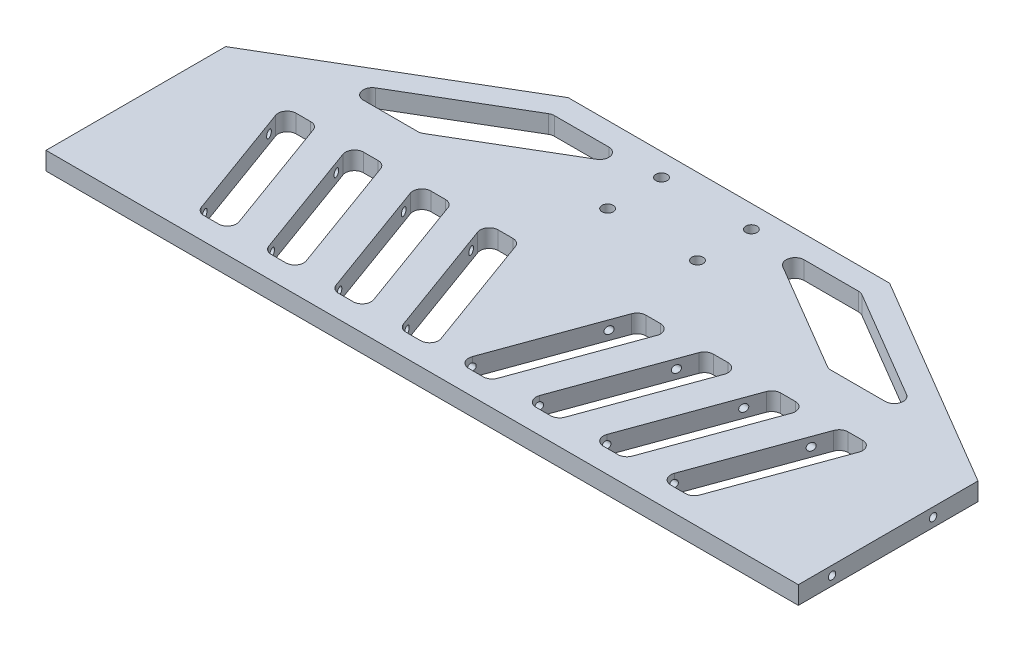
from build123d import *

# Parameters (mm, degrees)
SKIZZE3_R                       = 2.5
AUFSATZ_LINEAR_AUSTRAGEN2_DEPTH = 8
M4_GEWINDEBOHRUNG1_D            = 3.3
SCHNITT_LINEAR_AUSTRAGEN1_DEPTH = 8
SCHNITT_LINEAR_AUSTRAGEN2_DEPTH = 8


with BuildPart() as part:
    # Skizze3 → Aufsatz-Linear austragen2 (new body)
    with BuildSketch(Plane(origin=(0, 0, 0), x_dir=(1, 0, 0), z_dir=(0, 1, 0))):
        Polygon((167.5, -40), (-167.5, -40), (-167.5, 40), (-71.555705065, 96.578304299), (71.555705065, 96.578304299), (167.5, 40), align=None)
        with Locations((-20, 86.578304299)):
            Circle(SKIZZE3_R, mode=Mode.SUBTRACT)
        with Locations((-20, 62.578304299)):
            Circle(SKIZZE3_R, mode=Mode.SUBTRACT)
        with Locations((20, 62.578304299)):
            Circle(SKIZZE3_R, mode=Mode.SUBTRACT)
        with Locations((20, 86.578304299)):
            Circle(SKIZZE3_R, mode=Mode.SUBTRACT)
    extrude(amount=AUFSATZ_LINEAR_AUSTRAGEN2_DEPTH)

    # M4 Gewindebohrung1 (through all)
    with Locations(Plane(origin=(167.5, 0, 0), x_dir=(0, 0, -1), z_dir=(1, 0, 0))):
        with Locations((-25, 4), (20, 4)):
            Hole(M4_GEWINDEBOHRUNG1_D / 2)

    # Skizze7 → Schnitt-Linear austragen1 (cut)
    with BuildSketch(Plane(origin=(0, 8, 0), x_dir=(1, 0, 0), z_dir=(0, 1, 0))):
        with BuildLine():
            Line((-36.125622029, 30), (-29.639044209, 30))
            ThreePointArc((-29.639044209, 30), (-27.344738463, 29.276608177), (-25.880273726, 27.368080573))
            Line((-25.880273726, 27.368080573), (-6.953821544, -24.631919427))
            ThreePointArc((-6.953821544, -24.631919427), (-7.43598385, -28.294305745), (-10.712592027, -30))
            Line((-10.712592027, -30), (-17.199169847, -30))
            ThreePointArc((-17.199169847, -30), (-19.493475593, -29.276608177), (-20.95794033, -27.368080573))
            Line((-20.95794033, -27.368080573), (-39.884392512, 24.631919427))
            ThreePointArc((-39.884392512, 24.631919427), (-39.402230206, 28.294305745), (-36.125622029, 30))
        make_face()
        with BuildLine():
            Line((-55.880273726, 27.368080573), (-36.953821544, -24.631919427))
            ThreePointArc((-36.953821544, -24.631919427), (-37.43598385, -28.294305745), (-40.712592027, -30))
            Line((-40.712592027, -30), (-47.199169847, -30))
            ThreePointArc((-47.199169847, -30), (-49.493475593, -29.276608177), (-50.95794033, -27.368080573))
            Line((-50.95794033, -27.368080573), (-69.884392512, 24.631919427))
            ThreePointArc((-69.884392512, 24.631919427), (-69.402230206, 28.294305745), (-66.125622029, 30))
            Line((-66.125622029, 30), (-59.639044209, 30))
            ThreePointArc((-59.639044209, 30), (-57.344738463, 29.276608177), (-55.880273726, 27.368080573))
        make_face()
        with BuildLine():
            Line((-85.880273726, 27.368080573), (-66.953821544, -24.631919427))
            ThreePointArc((-66.953821544, -24.631919427), (-67.43598385, -28.294305745), (-70.712592027, -30))
            Line((-70.712592027, -30), (-77.199169847, -30))
            ThreePointArc((-77.199169847, -30), (-79.493475593, -29.276608177), (-80.95794033, -27.368080573))
            Line((-80.95794033, -27.368080573), (-99.884392512, 24.631919427))
            ThreePointArc((-99.884392512, 24.631919427), (-99.402230206, 28.294305745), (-96.125622029, 30))
            Line((-96.125622029, 30), (-89.639044209, 30))
            ThreePointArc((-89.639044209, 30), (-87.344738463, 29.276608177), (-85.880273726, 27.368080573))
        make_face()
        with BuildLine():
            Line((-115.880273726, 27.368080573), (-96.953821544, -24.631919427))
            ThreePointArc((-96.953821544, -24.631919427), (-97.43598385, -28.294305745), (-100.712592027, -30))
            Line((-100.712592027, -30), (-107.199169847, -30))
            ThreePointArc((-107.199169847, -30), (-109.493475593, -29.276608177), (-110.95794033, -27.368080573))
            Line((-110.95794033, -27.368080573), (-129.884392512, 24.631919427))
            ThreePointArc((-129.884392512, 24.631919427), (-129.402230206, 28.294305745), (-126.125622029, 30))
            Line((-126.125622029, 30), (-119.639044209, 30))
            ThreePointArc((-119.639044209, 30), (-117.344738463, 29.276608177), (-115.880273726, 27.368080573))
        make_face()
        with BuildLine():
            Line((126.125622029, 30), (119.639044209, 30))
            ThreePointArc((119.639044209, 30), (117.344738463, 29.276608177), (115.880273726, 27.368080573))
            Line((115.880273726, 27.368080573), (96.953821544, -24.631919427))
            ThreePointArc((96.953821544, -24.631919427), (97.43598385, -28.294305745), (100.712592027, -30))
            Line((100.712592027, -30), (107.199169847, -30))
            ThreePointArc((107.199169847, -30), (109.493475593, -29.276608177), (110.95794033, -27.368080573))
            Line((110.95794033, -27.368080573), (129.884392512, 24.631919427))
            ThreePointArc((129.884392512, 24.631919427), (129.402230206, 28.294305745), (126.125622029, 30))
        make_face()
        with BuildLine():
            Line((96.125622029, 30), (89.639044209, 30))
            ThreePointArc((89.639044209, 30), (87.344738463, 29.276608177), (85.880273726, 27.368080573))
            Line((85.880273726, 27.368080573), (66.953821544, -24.631919427))
            ThreePointArc((66.953821544, -24.631919427), (67.43598385, -28.294305745), (70.712592027, -30))
            Line((70.712592027, -30), (77.199169847, -30))
            ThreePointArc((77.199169847, -30), (79.493475593, -29.276608177), (80.95794033, -27.368080573))
            Line((80.95794033, -27.368080573), (99.884392512, 24.631919427))
            ThreePointArc((99.884392512, 24.631919427), (99.402230206, 28.294305745), (96.125622029, 30))
        make_face()
        with BuildLine():
            Line((66.125622029, 30), (59.639044209, 30))
            ThreePointArc((59.639044209, 30), (57.344738463, 29.276608177), (55.880273726, 27.368080573))
            Line((55.880273726, 27.368080573), (36.953821544, -24.631919427))
            ThreePointArc((36.953821544, -24.631919427), (37.43598385, -28.294305745), (40.712592027, -30))
            Line((40.712592027, -30), (47.199169847, -30))
            ThreePointArc((47.199169847, -30), (49.493475593, -29.276608177), (50.95794033, -27.368080573))
            Line((50.95794033, -27.368080573), (69.884392512, 24.631919427))
            ThreePointArc((69.884392512, 24.631919427), (69.402230206, 28.294305745), (66.125622029, 30))
        make_face()
        with BuildLine():
            Line((17.199169847, -30), (10.712592027, -30))
            ThreePointArc((10.712592027, -30), (7.43598385, -28.294305745), (6.953821544, -24.631919427))
            Line((6.953821544, -24.631919427), (25.880273726, 27.368080573))
            ThreePointArc((25.880273726, 27.368080573), (27.344738463, 29.276608177), (29.639044209, 30))
            Line((29.639044209, 30), (36.125622029, 30))
            ThreePointArc((36.125622029, 30), (39.402230206, 28.294305745), (39.884392512, 24.631919427))
            Line((39.884392512, 24.631919427), (20.95794033, -27.368080573))
            ThreePointArc((20.95794033, -27.368080573), (19.493475593, -29.276608177), (17.199169847, -30))
        make_face()
    extrude(amount=-SCHNITT_LINEAR_AUSTRAGEN1_DEPTH, mode=Mode.SUBTRACT)

    # Skizze8 → Schnitt-Linear austragen2 (cut)
    with BuildSketch(Plane(origin=(0, 8, 0), x_dir=(1, 0, 0), z_dir=(0, 1, 0))):
        with BuildLine():
            Line((-118.229526635, 57.445530058), (-69.767041052, 86.023834357))
            ThreePointArc((-69.767041052, 86.023834357), (-68.788275789, 86.437197938), (-67.735213643, 86.578304299))
            Line((-67.735213643, 86.578304299), (-43.484582842, 86.578304299))
            ThreePointArc((-43.484582842, 86.578304299), (-39.625689203, 83.631366445), (-41.452755434, 79.13277424))
            Line((-41.452755434, 79.13277424), (-89.915241017, 50.554469942))
            ThreePointArc((-89.915241017, 50.554469942), (-90.894006279, 50.141106361), (-91.947068425, 50))
            Line((-91.947068425, 50), (-116.197699226, 50))
            ThreePointArc((-116.197699226, 50), (-120.056592865, 52.946937854), (-118.229526635, 57.445530058))
        make_face()
        with BuildLine():
            Line((89.915241017, 50.554469942), (41.452755434, 79.13277424))
            ThreePointArc((41.452755434, 79.13277424), (39.625689203, 83.631366445), (43.484582842, 86.578304299))
            Line((43.484582842, 86.578304299), (67.735213643, 86.578304299))
            ThreePointArc((67.735213643, 86.578304299), (68.788275789, 86.437197938), (69.767041052, 86.023834357))
            Line((69.767041052, 86.023834357), (118.229526635, 57.445530058))
            ThreePointArc((118.229526635, 57.445530058), (120.056592865, 52.946937854), (116.197699226, 50))
            Line((116.197699226, 50), (91.947068425, 50))
            ThreePointArc((91.947068425, 50), (90.894006279, 50.141106361), (89.915241017, 50.554469942))
        make_face()
    extrude(amount=-SCHNITT_LINEAR_AUSTRAGEN2_DEPTH, mode=Mode.SUBTRACT)


solid = part.part
